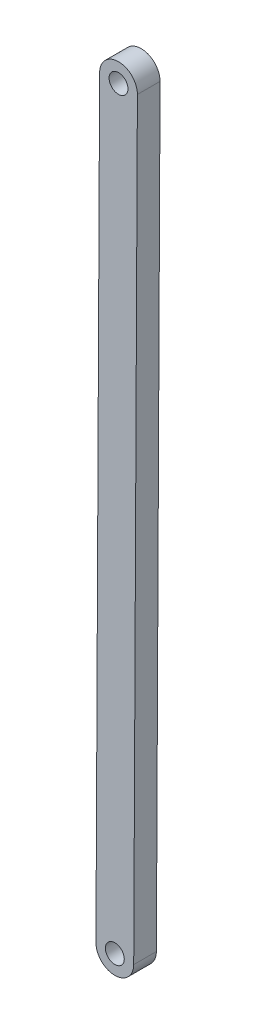
from build123d import *

# Parameters (mm, degrees)
SKETCH1_R           = 5
BOSS_EXTRUDE1_DEPTH = 6


with BuildPart() as part:
    # Sketch1 → Boss-Extrude1 (new body)
    with BuildSketch(Plane.XY):
        with BuildLine():
            Line((9.999881276, -0.048728438), (8.050720605, -400.048728438))
            ThreePointArc((8.050720605, -400.048728438), (-1.99788911, -409.999881276), (-11.949041948, -399.951271562))
            Line((-11.949041948, -399.951271562), (-9.999881276, 0.048728438))
            ThreePointArc((-9.999881276, 0.048728438), (0.048728438, 9.999881276), (9.999881276, -0.048728438))
        make_face()
        with Locations((-1.949160671, -400)):
            Circle(SKETCH1_R, mode=Mode.SUBTRACT)
        Circle(SKETCH1_R, mode=Mode.SUBTRACT)
    boss_extrude1 = extrude(amount=BOSS_EXTRUDE1_DEPTH)

    # Mirror1: Boss-Extrude1 across plane
    add(boss_extrude1.mirror(Plane.XY))


solid = part.part
